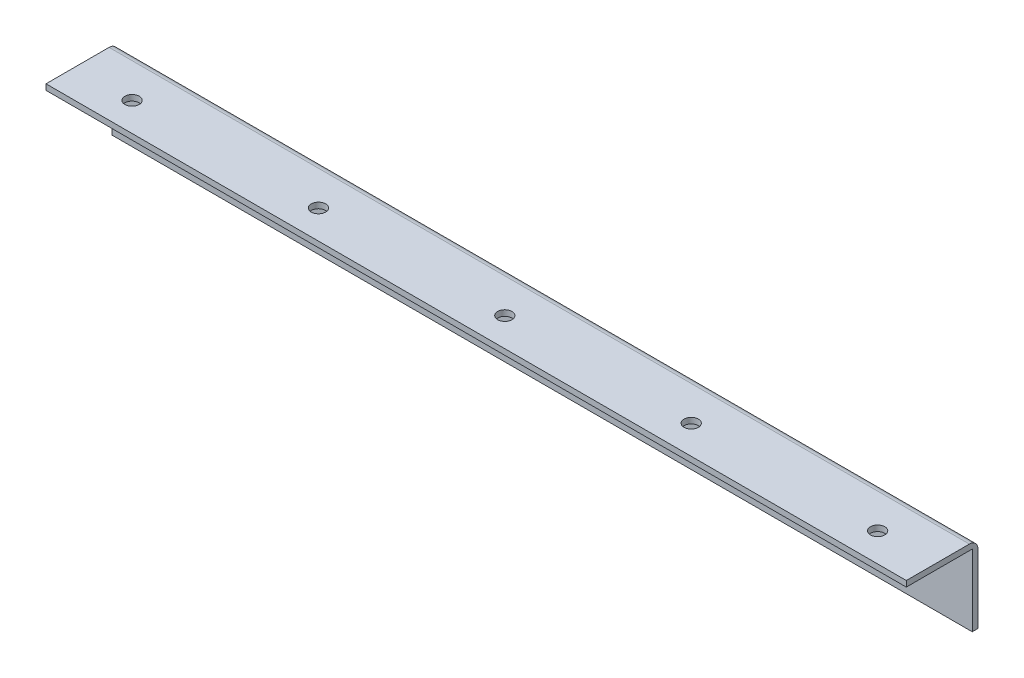
from build123d import *

# Parameters (mm, degrees)
ESBO_O1_W                = 300
ESBO_O1_H                = 25
RESSALTO_EXTRUS_O1_DEPTH = 2
ESBO_O2_R                = 2.5
CORTE_EXTRUS_O1_DEPTH    = 3
ESBO_O3_W                = 300
ESBO_O3_H                = 2
RESSALTO_EXTRUS_O2_DEPTH = 25
FILETE1_R                = 3


with BuildPart() as part:
    # Esboço1 → Ressalto-extrusão1 (new body)
    with BuildSketch(Plane(origin=(0, 0, 0), x_dir=(1, 0, 0), z_dir=(0, 1, 0))):
        Rectangle(ESBO_O1_W, ESBO_O1_H)
    extrude(amount=RESSALTO_EXTRUS_O1_DEPTH)

    # Esboço2 → Corte-extrusão1 (cut, through all)
    with BuildSketch(Plane(origin=(0, 2, 0), x_dir=(1, 0, 0), z_dir=(0, 1, 0))):
        with Locations((-130, -2.5)):
            Circle(ESBO_O2_R)
        with Locations((-65, -2.5)):
            Circle(ESBO_O2_R)
        with Locations((0, -2.5)):
            Circle(ESBO_O2_R)
        with Locations((65, -2.5)):
            Circle(ESBO_O2_R)
        with Locations((130, -2.5)):
            Circle(ESBO_O2_R)
    extrude(amount=-CORTE_EXTRUS_O1_DEPTH, mode=Mode.SUBTRACT)

    # Esboço3 → Ressalto-extrusão2 (add)
    with BuildSketch(Plane.XZ):
        with Locations((0, -11.5)):
            Rectangle(ESBO_O3_W, ESBO_O3_H)
    extrude(amount=RESSALTO_EXTRUS_O2_DEPTH)

    # Filete1
    filete1_edges = [part.edges().sort_by_distance(p)[0] for p in [
        (0, 2, -12.5),
    ]]
    fillet(filete1_edges, radius=FILETE1_R)


solid = part.part
